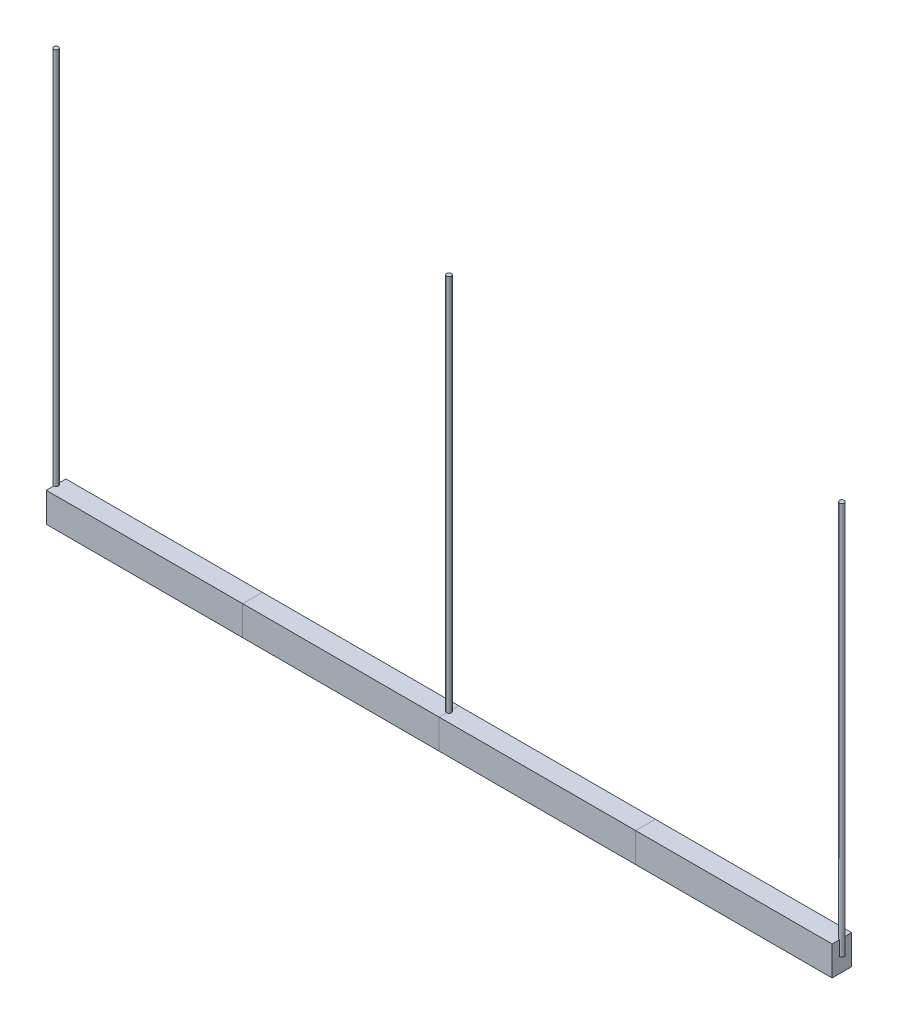
from build123d import *

# Parameters (mm, degrees)
SKETCH1_W        = 100
SKETCH1_H        = 150
SEGMENT_1_DEPTH  = 1000
SKETCH2_W        = 100
SKETCH2_H        = 150
SEGMENT_2_DEPTH  = 1000
SKETCH3_W        = 100
SKETCH3_H        = 150
SEGMENT_3_DEPTH  = 1000
SKETCH4_W        = 100
SKETCH4_H        = 150
SEGMENT_4_DEPTH  = 1000
SKETCH5_R        = 12
LINKAGES_DEPTH   = 2000
LINKAGES_2_DEPTH = 2000
LINKAGES_3_DEPTH = 2000


with BuildPart() as part:
    # Sketch1 → Segment 1 (new body)
    with BuildSketch(Plane(origin=(0, 0, 0), x_dir=(0, 0, -1), z_dir=(1, 0, 0))):
        Rectangle(SKETCH1_W, SKETCH1_H)
    extrude(amount=SEGMENT_1_DEPTH)


with BuildPart() as body_2:
    # Sketch2 → Segment 2 (new body)
    with BuildSketch(Plane(origin=(1000, 0, 0), x_dir=(0, 0, -1), z_dir=(1, 0, 0))):
        Rectangle(SKETCH2_W, SKETCH2_H)
    extrude(amount=SEGMENT_2_DEPTH)


with BuildPart() as body_3:
    # Sketch3 → Segment 3 (new body)
    with BuildSketch(Plane(origin=(2000, 0, 0), x_dir=(0, 0, -1), z_dir=(1, 0, 0))):
        Rectangle(SKETCH3_W, SKETCH3_H)
    extrude(amount=SEGMENT_3_DEPTH)


with BuildPart() as body_4:
    # Sketch4 → Segment 4 (new body)
    with BuildSketch(Plane(origin=(3000, 0, 0), x_dir=(0, 0, -1), z_dir=(1, 0, 0))):
        Rectangle(SKETCH4_W, SKETCH4_H)
    extrude(amount=SEGMENT_4_DEPTH)


with BuildPart() as body_5:
    # Sketch5 → Linkages (new body)
    with BuildSketch(Plane(origin=(0, 0, 0), x_dir=(1, 0, 0), z_dir=(0, 1, 0))):
        Circle(SKETCH5_R)
    extrude(amount=LINKAGES_DEPTH)


with BuildPart() as body_6:
    # Sketch5 → Linkages 2 (new body)
    with BuildSketch(Plane(origin=(0, 0, 0), x_dir=(1, 0, 0), z_dir=(0, 1, 0))):
        with Locations((2000, 0)):
            Circle(SKETCH5_R)
    extrude(amount=LINKAGES_2_DEPTH)


with BuildPart() as body_7:
    # Sketch5 → Linkages 3 (new body)
    with BuildSketch(Plane(origin=(0, 0, 0), x_dir=(1, 0, 0), z_dir=(0, 1, 0))):
        with Locations((4000, 0)):
            Circle(SKETCH5_R)
    extrude(amount=LINKAGES_3_DEPTH)


solid = Compound([part.part, body_2.part, body_3.part, body_4.part, body_5.part, body_6.part, body_7.part])
